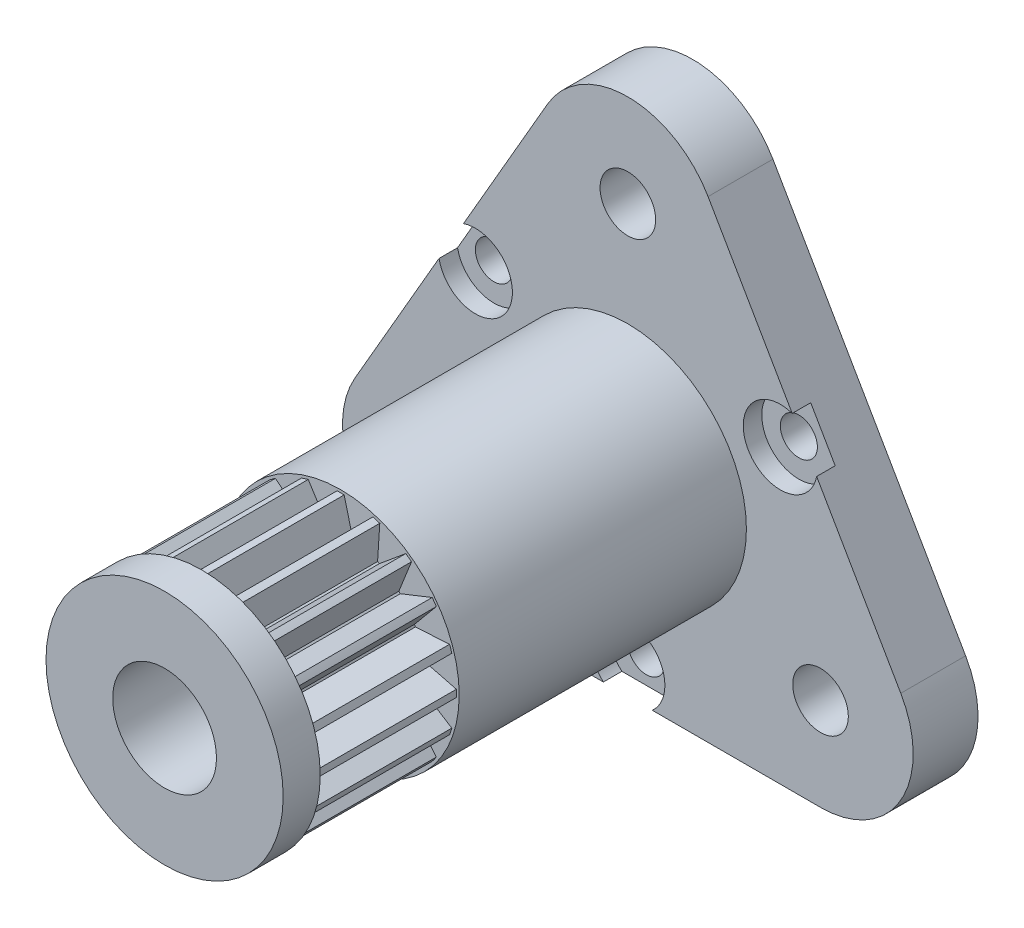
from build123d import *

# Parameters (mm, degrees)
SKETCH1_R               = 1.5
BOSS_EXTRUDE1_DEPTH     = 3.5
SKETCH2_R               = 6.4
BOSS_EXTRUDE2_DEPTH     = 25
SKETCH3_R               = 2.8
CUT_EXTRUDE1_DEPTH      = 29.5
SKETCH6_R               = 9.569614172
CUT_EXTRUDE6_DEPTH      = 7.5
SKETCH7_R               = 17.775779512
SKETCH7_R_2             = 6.25
CUT_EXTRUDE7_DEPTH      = 7.5
SKETCH8_R               = 1
CUT_EXTRUDE8_DEPTH      = 4.5
SKETCH9_R               = 2
CUT_EXTRUDE9_DEPTH      = 13
CUT_EXTRUDE9_DEPTH_BACK = 1


with BuildPart() as part:
    # Sketch1 → Boss-Extrude1 (new body)
    with BuildSketch(Plane.XY):
        with BuildLine():
            Line((-14.730127019, -3.5044428), (-4.330127019, 14.508885599))
            ThreePointArc((-4.330127019, 14.508885599), (0, 17.008885599), (4.330127019, 14.508885599))
            Line((4.330127019, 14.508885599), (14.730127019, -3.5044428))
            ThreePointArc((14.730127019, -3.5044428), (14.730127019, -8.5044428), (10.4, -11.0044428))
            Line((10.4, -11.0044428), (-10.4, -11.0044428))
            ThreePointArc((-10.4, -11.0044428), (-14.730127019, -8.5044428), (-14.730127019, -3.5044428))
        make_face()
        with Locations((0, 12.008885599)):
            Circle(SKETCH1_R, mode=Mode.SUBTRACT)
        with Locations((-10.4, -6.0044428)):
            Circle(SKETCH1_R, mode=Mode.SUBTRACT)
        with Locations((10.4, -6.0044428)):
            Circle(SKETCH1_R, mode=Mode.SUBTRACT)
    extrude(amount=BOSS_EXTRUDE1_DEPTH)

    # Sketch2 → Boss-Extrude2 (add)
    with BuildSketch(Plane.XY.offset(3.5)):
        Circle(SKETCH2_R)
    extrude(amount=BOSS_EXTRUDE2_DEPTH)

    # Sketch3 → Cut-Extrude1 (cut, through all)
    with BuildSketch(Plane.XY.offset(28.5)):
        Circle(SKETCH3_R)
    extrude(amount=-CUT_EXTRUDE1_DEPTH, mode=Mode.SUBTRACT)

    # Sketch6 → Cut-Extrude6 (cut)
    with BuildSketch(Plane.XY.offset(26.5)):
        Circle(SKETCH6_R)
        Polygon((7, 0), (4.452808103, 0.65), (4.435733208, 0.757806641), (6.657395614, 2.163118961), (4.034011116, 1.994180112), (3.984457842, 2.091433888), (5.663118961, 4.114496766), (3.220337014, 3.14315598), (3.14315598, 3.220337014), (4.114496766, 5.663118961), (2.091433888, 3.984457842), (1.994180112, 4.034011116), (2.163118961, 6.657395614), (0.757806641, 4.435733208), (0.65, 4.452808103), (0, 7), (-0.65, 4.452808103), (-0.757806641, 4.435733208), (-2.163118961, 6.657395614), (-1.994180112, 4.034011116), (-2.091433888, 3.984457842), (-4.114496766, 5.663118961), (-3.14315598, 3.220337014), (-3.220337014, 3.14315598), (-5.663118961, 4.114496766), (-3.984457842, 2.091433888), (-4.034011116, 1.994180112), (-6.657395614, 2.163118961), (-4.435733208, 0.757806641), (-4.452808103, 0.65), (-7, 0), (-4.452808103, -0.65), (-4.435733208, -0.757806641), (-6.657395614, -2.163118961), (-4.034011116, -1.994180112), (-3.984457842, -2.091433888), (-5.663118961, -4.114496766), (-3.220337014, -3.14315598), (-3.14315598, -3.220337014), (-4.114496766, -5.663118961), (-2.091433888, -3.984457842), (-1.994180112, -4.034011116), (-2.163118961, -6.657395614), (-0.757806641, -4.435733208), (-0.65, -4.452808103), (0, -7), (0.65, -4.452808103), (0.757806641, -4.435733208), (2.163118961, -6.657395614), (1.994180112, -4.034011116), (2.091433888, -3.984457842), (4.114496766, -5.663118961), (3.14315598, -3.220337014), (3.220337014, -3.14315598), (5.663118961, -4.114496766), (3.984457842, -2.091433888), (4.034011116, -1.994180112), (6.657395614, -2.163118961), (4.435733208, -0.757806641), (4.452808103, -0.65), align=None, mode=Mode.SUBTRACT)
    extrude(amount=-CUT_EXTRUDE6_DEPTH, mode=Mode.SUBTRACT)

    # Sketch7 → Cut-Extrude7 (cut)
    with BuildSketch(Plane.XY.offset(26.5)):
        Circle(SKETCH7_R)
        Circle(SKETCH7_R_2, mode=Mode.SUBTRACT)
    extrude(amount=-CUT_EXTRUDE7_DEPTH, mode=Mode.SUBTRACT)

    # Sketch8 → Cut-Extrude8 (cut, through all)
    with BuildSketch(Plane.XY.offset(3.5)):
        with Locations((8.229165125, 4.7511107)):
            Circle(SKETCH8_R)
        with Locations((0, -9.5022214)):
            Circle(SKETCH8_R)
        with Locations((-8.229165125, 4.7511107)):
            Circle(SKETCH8_R)
    extrude(amount=-CUT_EXTRUDE8_DEPTH, mode=Mode.SUBTRACT)

    # Sketch9 → Cut-Extrude9 (cut, two sides)
    with BuildSketch(Plane.XY.offset(3.5)) as cut_extrude9_sk:
        with Locations((8.229165125, 4.7511107)):
            Circle(SKETCH9_R)
        with Locations((0, -9.5022214)):
            Circle(SKETCH9_R)
        with Locations((-8.229165125, 4.7511107)):
            Circle(SKETCH9_R)
    extrude(amount=CUT_EXTRUDE9_DEPTH, mode=Mode.SUBTRACT)
    extrude(cut_extrude9_sk.sketch, amount=-CUT_EXTRUDE9_DEPTH_BACK, mode=Mode.SUBTRACT)


solid = part.part
